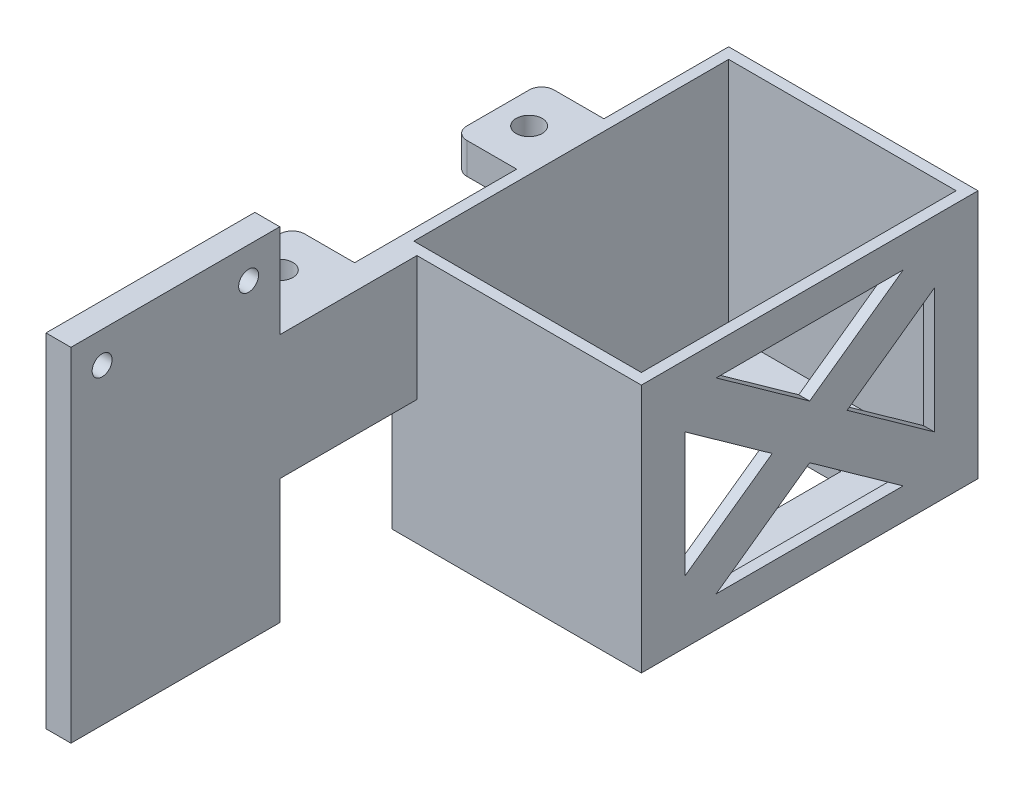
from build123d import *

# Parameters (mm, degrees)
SKETCH2_W             = 10
SKETCH2_H             = 14
SKETCH2_R             = 2.1
BOSS_EXTRUDE1_DEPTH   = 5
BOSS_EXTRUDE1_2_DEPTH = 5
SKETCH3_W             = 44.5
SKETCH3_H             = 39
SKETCH3_W_2           = 14
SKETCH3_H_2           = 5
BOSS_EXTRUDE2_DEPTH   = 2
BOSS_EXTRUDE4_DEPTH   = 32
SKETCH5_W             = 2
SKETCH5_H             = 85
BOSS_EXTRUDE5_DEPTH   = 37
SKETCH6_W             = 14
SKETCH6_H             = 30
CUT_EXTRUDE1_DEPTH    = 200
SKETCH7_W             = 20
SKETCH7_H             = 20
CUT_EXTRUDE2_DEPTH    = 16
FILLET1_R             = 2
SKETCH8_W             = 95.919235743
SKETCH8_H             = 46.663411984
CUT_EXTRUDE4_DEPTH    = 34
SKETCH9_W             = 7
SKETCH9_H             = 5
BOSS_EXTRUDE6_DEPTH   = 2
BOSS_EXTRUDE9_DEPTH   = 36
BOSS_EXTRUDE9_2_DEPTH = 36
SKETCH12_W            = 50
SKETCH12_H            = 2
CUT_EXTRUDE5_DEPTH    = 36
SKETCH13_W            = 50
SKETCH13_H            = 2
BOSS_EXTRUDE11_DEPTH  = 36
BOSS_EXTRUDE12_DEPTH  = 2
SKETCH15_W            = 54
SKETCH15_H            = 40
BOSS_EXTRUDE13_DEPTH  = 2
CUT_EXTRUDE6_DEPTH    = 2
SKETCH17_W            = 55
SKETCH17_H            = 37
BOSS_EXTRUDE14_DEPTH  = 4
SKETCH18_R            = 1.6
CUT_EXTRUDE7_DEPTH    = 11
SKETCH19_R            = 1.6
BOSS_EXTRUDE15_DEPTH  = 4
SKETCH20_R            = 3.6
CUT_EXTRUDE8_DEPTH    = 2.2
SKETCH21_W            = 56.91688516
SKETCH21_H            = 39.408005253
CUT_EXTRUDE9_DEPTH    = 4
SKETCH22_W            = 37.5
SKETCH22_H            = 27.5
SKETCH22_R            = 1.6
BOSS_EXTRUDE16_DEPTH  = 2
SKETCH23_W            = 30
SKETCH23_H            = 12.5
BOSS_EXTRUDE17_DEPTH  = 2
SKETCH25_W            = 20
SKETCH25_H            = 30
CUT_EXTRUDE10_DEPTH   = 15
SKETCH26_R            = 1.6
SKETCH26_W            = 37.5
SKETCH26_H            = 27.5
BOSS_EXTRUDE18_DEPTH  = 2
SKETCH27_W            = 37.5
SKETCH27_H            = 27.5
BOSS_EXTRUDE19_DEPTH  = 2
SKETCH28_W            = 36.5
SKETCH28_H            = 50.5
CUT_EXTRUDE11_DEPTH   = 38
SKETCH29_W            = 33.5
SKETCH29_H            = 55
SKETCH29_R            = 1.6
BOSS_EXTRUDE20_DEPTH  = 4
SKETCH30_W            = 12
SKETCH30_H            = 55
CUT_EXTRUDE12_DEPTH   = 4
SKETCH31_R            = 1.6
CUT_EXTRUDE13_DEPTH   = 4
SKETCH32_W            = 22
SKETCH32_H            = 20
BOSS_EXTRUDE21_DEPTH  = 4


with BuildPart() as part:
    # Sketch2 → Boss-Extrude1 (new body)
    with BuildSketch(Plane(origin=(0, 0, 0), x_dir=(1, 0, 0), z_dir=(0, 1, 0))):
        with Locations((114.448385229, -132.360414745)):
            Rectangle(SKETCH2_W, SKETCH2_H)
        with Locations((114.448385229, -132.360414745)):
            Circle(SKETCH2_R, mode=Mode.SUBTRACT)
    extrude(amount=BOSS_EXTRUDE1_DEPTH)



with BuildPart() as body_2:
    # Sketch2 → Boss-Extrude1 2 (new body)
    with BuildSketch(Plane(origin=(0, 0, 0), x_dir=(1, 0, 0), z_dir=(0, 1, 0))):
        with Locations((114.448385229, -172.360414745)):
            Rectangle(SKETCH2_W, SKETCH2_H)
        with Locations((114.448385229, -172.360414745)):
            Circle(SKETCH2_R, mode=Mode.SUBTRACT)
    extrude(amount=BOSS_EXTRUDE1_2_DEPTH)


with BuildPart() as part_1:
    add(part.part)

    add(body_2.part)  # Boss-Extrude2 merges body 2
    # Sketch3 → Boss-Extrude2 (add)
    with BuildSketch(Plane(origin=(119.448385229, 0, 0), x_dir=(0, 0, -1), z_dir=(1, 0, 0))):
        Polygon((-152.360414745, -34), (-152.360414745, 5), (-165.360414745, 5), (-165.360414745, 0), (-179.360414745, 0), (-179.360414745, 5), (-196.860414745, 5), (-196.860414745, -34), align=None)
        with Locations((-130.110414745, -14.5)):
            Rectangle(SKETCH3_W, SKETCH3_H)
        with Locations((-172.360414745, 2.5)):
            Rectangle(SKETCH3_W_2, SKETCH3_H_2)
    extrude(amount=BOSS_EXTRUDE2_DEPTH)

    # Sketch4 → Boss-Extrude4 (add)
    with BuildSketch(Plane(origin=(121.448385229, 0, 0), x_dir=(0, 0, -1), z_dir=(1, 0, 0))):
        Polygon((-194.860414745, 5), (-196.860414745, 5), (-196.860414745, -34), (-107.860414745, -34), (-107.860414745, 5), (-109.860414745, 5), (-109.860414745, -32), (-194.860414745, -32), align=None)
    extrude(amount=BOSS_EXTRUDE4_DEPTH)

    # Sketch5 → Boss-Extrude5 (add)
    with BuildSketch(Plane(origin=(0, -32, 0), x_dir=(1, 0, 0), z_dir=(0, 1, 0))):
        with Locations((152.448385229, -152.360414745)):
            Rectangle(SKETCH5_W, SKETCH5_H)
    extrude(amount=BOSS_EXTRUDE5_DEPTH)

    # Sketch6 → Cut-Extrude1 (cut)
    with BuildSketch(Plane.XY.offset(196.860414745)):
        with Locations((136.448385229, -10)):
            Rectangle(SKETCH6_W, SKETCH6_H)
    extrude(amount=-CUT_EXTRUDE1_DEPTH, mode=Mode.SUBTRACT)

    # Sketch7 → Cut-Extrude2 (cut)
    with BuildSketch(Plane(origin=(153.448385229, 0, 0), x_dir=(0, 0, -1), z_dir=(1, 0, 0))):
        with Locations((-179.360414745, -14.5)):
            Rectangle(SKETCH7_W, SKETCH7_H)
        with Locations((-152.360414745, -14.5)):
            Rectangle(SKETCH7_W, SKETCH7_H)
        with Locations((-125.360414745, -14.5)):
            Rectangle(SKETCH7_W, SKETCH7_H)
    extrude(amount=-CUT_EXTRUDE2_DEPTH, mode=Mode.SUBTRACT)

    # Fillet1
    fillet1_edges = [part_1.edges().sort_by_distance(p)[0] for p in [
        (109.448385229, 2.5, 139.360414745),
        (109.448385229, 2.5, 125.360414745),
        (109.448385229, 2.5, 179.360414745),
        (109.448385229, 2.5, 165.360414745),
    ]]
    fillet(fillet1_edges, radius=FILLET1_R)

    # Sketch8 → Cut-Extrude4 (cut)
    with BuildSketch(Plane(origin=(153.448385229, 0, 0), x_dir=(0, 0, -1), z_dir=(1, 0, 0))):
        with Locations((-152.759247327, -15.092668453)):
            Rectangle(SKETCH8_W, SKETCH8_H)
    extrude(amount=-CUT_EXTRUDE4_DEPTH, mode=Mode.SUBTRACT)

    # Sketch9 → Boss-Extrude6 (add)
    with BuildSketch(Plane(origin=(119.448385229, 0, 0), x_dir=(0, 0, -1), z_dir=(1, 0, 0))):
        Polygon((-132.360414745, 0), (-132.360414745, -35), (-107.360414745, -35), (-107.360414745, 5), (-125.360414745, 5), (-125.360414745, 0), align=None)
        Polygon((-157.360414745, 5), (-157.360414745, -35), (-132.360414745, -35), (-132.360414745, 0), (-139.360414745, 0), (-139.360414745, 5), align=None)
        with Locations((-135.860414745, 2.5)):
            Rectangle(SKETCH9_W, SKETCH9_H)
        with Locations((-128.860414745, 2.5)):
            Rectangle(SKETCH9_W, SKETCH9_H)
    extrude(amount=BOSS_EXTRUDE6_DEPTH)

    # Sketch12 → Cut-Extrude5 (cut)
    with BuildSketch(Plane(origin=(121.448385229, 0, 0), x_dir=(0, 0, -1), z_dir=(1, 0, 0))):
        with Locations((-132.360414745, -34)):
            Rectangle(SKETCH12_W, SKETCH12_H)
    extrude(amount=-CUT_EXTRUDE5_DEPTH, mode=Mode.SUBTRACT)



with BuildPart() as body_2_2:
    # Sketch11 → Boss-Extrude9 (new body)
    with BuildSketch(Plane(origin=(121.448385229, 0, 0), x_dir=(0, 0, -1), z_dir=(1, 0, 0))):
        Polygon((-157.360414745, -33), (-157.360414745, 5), (-159.360414745, 5), (-159.360414745, -35), (-157.360414745, -35), align=None)
    extrude(amount=BOSS_EXTRUDE9_DEPTH)



with BuildPart() as body_3:
    # Sketch11 → Boss-Extrude9 2 (new body)
    with BuildSketch(Plane(origin=(121.448385229, 0, 0), x_dir=(0, 0, -1), z_dir=(1, 0, 0))):
        Polygon((-107.360414745, 5), (-107.360414745, -33), (-107.360414745, -35), (-105.360414745, -35), (-105.360414745, 5), align=None)
    extrude(amount=BOSS_EXTRUDE9_2_DEPTH)


with BuildPart() as body_2_2_1:
    add(body_2_2.part)

    add(body_3.part)  # Boss-Extrude11 merges body 3
    # Sketch13 → Boss-Extrude11 (add)
    with BuildSketch(Plane(origin=(121.448385229, 0, 0), x_dir=(0, 0, -1), z_dir=(1, 0, 0))):
        with Locations((-132.360414745, -34)):
            Rectangle(SKETCH13_W, SKETCH13_H)
    extrude(amount=BOSS_EXTRUDE11_DEPTH)


with BuildPart() as part_2:
    add(part_1.part)

    add(body_2_2_1.part)  # Boss-Extrude12 merges body 2 2
    # Sketch14 → Boss-Extrude12 (add)
    with BuildSketch(Plane.ZY.offset(-121.448385229)):
        Polygon((107.360414745, 5), (105.360414745, 5), (105.360414745, -35), (159.360414745, -35), (159.360414745, 5), (157.360414745, 5), (157.360414745, -33), (107.360414745, -33), align=None)
    extrude(amount=BOSS_EXTRUDE12_DEPTH)

    # Sketch15 → Boss-Extrude13 (add)
    with BuildSketch(Plane(origin=(157.448385229, 0, 0), x_dir=(0, 0, -1), z_dir=(1, 0, 0))):
        with Locations((-132.360414745, -15)):
            Rectangle(SKETCH15_W, SKETCH15_H)
    extrude(amount=BOSS_EXTRUDE13_DEPTH)

    # Sketch16 → Cut-Extrude6 (cut)
    with BuildSketch(Plane(origin=(159.448385229, 0, 0), x_dir=(0, 0, -1), z_dir=(1, 0, 0))):
        Polygon((-138.360414745, -15), (-152.360414745, -5), (-152.360414745, -25), align=None)
        Polygon((-147.360414745, 0), (-132.360414745, -10.714285714), (-117.360414745, 0), align=None)
        Polygon((-112.360414745, -5), (-126.360414745, -15), (-112.360414745, -25), align=None)
        Polygon((-117.360414745, -30), (-132.360414745, -19.285714286), (-147.360414745, -30), align=None)
    extrude(amount=-CUT_EXTRUDE6_DEPTH, mode=Mode.SUBTRACT)

    # Sketch17 → Boss-Extrude14 (add)
    with BuildSketch(Plane(origin=(119.448385229, 0, 0), x_dir=(0, 0, -1), z_dir=(1, 0, 0))):
        with Locations((-186.860414745, -13.5)):
            Rectangle(SKETCH17_W, SKETCH17_H)
    extrude(amount=BOSS_EXTRUDE14_DEPTH)

    # Sketch18 → Cut-Extrude7 (cut)
    with BuildSketch(Plane(origin=(123.448385229, 0, 0), x_dir=(0, 0, -1), z_dir=(1, 0, 0))):
        with Locations((-209.360414745, -1.75)):
            Circle(SKETCH18_R)
        with Locations((-209.360414745, -25.25)):
            Circle(SKETCH18_R)
        with Locations((-164.360414745, -25.25)):
            Circle(SKETCH18_R)
        with Locations((-164.360414745, -1.75)):
            Circle(SKETCH18_R)
    extrude(amount=-CUT_EXTRUDE7_DEPTH, mode=Mode.SUBTRACT)

    # Sketch19 → Boss-Extrude15 (add)
    with BuildSketch(Plane.ZY.offset(-119.448385229)):
        with Locations((164.360414745, -1.75)):
            Circle(SKETCH19_R)
    extrude(amount=-BOSS_EXTRUDE15_DEPTH)

    # Sketch20 → Cut-Extrude8 (cut)
    with BuildSketch(Plane.ZY.offset(-119.448385229)):
        with Locations((209.360414745, -1.75)):
            Circle(SKETCH20_R)
        with Locations((209.360414745, -25.25)):
            Circle(SKETCH20_R)
        with Locations((164.360414745, -25.25)):
            Circle(SKETCH20_R)
    extrude(amount=-CUT_EXTRUDE8_DEPTH, mode=Mode.SUBTRACT)

    # Sketch21 → Cut-Extrude9 (cut)
    with BuildSketch(Plane(origin=(123.448385229, 0, 0), x_dir=(0, 0, -1), z_dir=(1, 0, 0))):
        with Locations((-187.818857325, -12.295997374)):
            Rectangle(SKETCH21_W, SKETCH21_H)
    extrude(amount=-CUT_EXTRUDE9_DEPTH, mode=Mode.SUBTRACT)



with BuildPart() as body_2_3:
    # Sketch22 → Boss-Extrude16 (new body)
    with BuildSketch(Plane(origin=(119.448385229, 0, 0), x_dir=(0, 0, -1), z_dir=(1, 0, 0))):
        with Locations((-208.110414745, 6.25)):
            Rectangle(SKETCH22_W, SKETCH22_H)
        with Locations((-219.860414745, 15)):
            Circle(SKETCH22_R, mode=Mode.SUBTRACT)
        with Locations((-196.360414745, 15)):
            Circle(SKETCH22_R, mode=Mode.SUBTRACT)
    extrude(amount=BOSS_EXTRUDE16_DEPTH)


with BuildPart() as part_3:
    add(part_2.part)

    add(body_2_3.part)  # Boss-Extrude17 merges body 2 3
    # Sketch23 → Boss-Extrude17 (add)
    with BuildSketch(Plane(origin=(119.448385229, 0, 0), x_dir=(0, 0, -1), z_dir=(1, 0, 0))):
        with Locations((-174.360414745, -1.25)):
            Rectangle(SKETCH23_W, SKETCH23_H)
    extrude(amount=BOSS_EXTRUDE17_DEPTH)

    # Sketch25 → Cut-Extrude10 (cut)
    with BuildSketch(Plane(origin=(0, -35, 0), x_dir=(-1, 0, 0), z_dir=(0, -1, 0))):
        with Locations((-139.448385229, -132.360414745)):
            Rectangle(SKETCH25_W, SKETCH25_H)
    extrude(amount=-CUT_EXTRUDE10_DEPTH, mode=Mode.SUBTRACT)

    # Sketch26 → Boss-Extrude18 (add)
    with BuildSketch(Plane(origin=(121.448385229, 0, 0), x_dir=(0, 0, -1), z_dir=(1, 0, 0))):
        Polygon((-226.860414745, -7.5), (-159.360414745, -7.5), (-159.360414745, 5), (-189.360414745, 5), (-189.360414745, 20), (-226.860414745, 20), align=None)
        with Locations((-219.860414745, 15)):
            Circle(SKETCH26_R, mode=Mode.SUBTRACT)
        with Locations((-196.360414745, 15)):
            Circle(SKETCH26_R, mode=Mode.SUBTRACT)
        with Locations((-208.110414745, -21.25)):
            Rectangle(SKETCH26_W, SKETCH26_H)
    extrude(amount=BOSS_EXTRUDE18_DEPTH)

    # Sketch27 → Boss-Extrude19 (add)
    with BuildSketch(Plane.ZY.offset(-121.448385229)):
        with Locations((208.110414745, -21.25)):
            Rectangle(SKETCH27_W, SKETCH27_H)
    extrude(amount=BOSS_EXTRUDE19_DEPTH)

    # Sketch28 → Cut-Extrude11 (cut)
    with BuildSketch(Plane(origin=(0, 5, 0), x_dir=(1, 0, 0), z_dir=(0, 1, 0))):
        with Locations((139.448385229, -132.360414745)):
            Rectangle(SKETCH28_W, SKETCH28_H)
    extrude(amount=-CUT_EXTRUDE11_DEPTH, mode=Mode.SUBTRACT)

    # Sketch29 → Boss-Extrude20 (add)
    with BuildSketch(Plane(origin=(123.448385229, 0, 0), x_dir=(0, 0, -1), z_dir=(1, 0, 0))):
        with Locations((-198.110414745, -7.5)):
            Rectangle(SKETCH29_W, SKETCH29_H)
        with Locations((-186.360414745, 15)):
            Circle(SKETCH29_R, mode=Mode.SUBTRACT)
        with Locations((-209.860414745, 15)):
            Circle(SKETCH29_R, mode=Mode.SUBTRACT)
    extrude(amount=-BOSS_EXTRUDE20_DEPTH)

    # Sketch30 → Cut-Extrude12 (cut)
    with BuildSketch(Plane(origin=(123.448385229, 0, 0), x_dir=(0, 0, -1), z_dir=(1, 0, 0))):
        with Locations((-220.860414745, -7.5)):
            Rectangle(SKETCH30_W, SKETCH30_H)
    extrude(amount=-CUT_EXTRUDE12_DEPTH, mode=Mode.SUBTRACT)

    # Sketch31 → Cut-Extrude13 (cut)
    with BuildSketch(Plane(origin=(123.448385229, 0, 0), x_dir=(0, 0, -1), z_dir=(1, 0, 0))):
        with Locations((-209.860414745, 15)):
            Circle(SKETCH31_R)
    extrude(amount=-CUT_EXTRUDE13_DEPTH, mode=Mode.SUBTRACT)

    # Sketch32 → Boss-Extrude21 (add)
    with BuildSketch(Plane(origin=(123.448385229, 0, 0), x_dir=(0, 0, -1), z_dir=(1, 0, 0))):
        with Locations((-170.360414745, -5)):
            Rectangle(SKETCH32_W, SKETCH32_H)
    extrude(amount=-BOSS_EXTRUDE21_DEPTH)


solid = part_3.part
